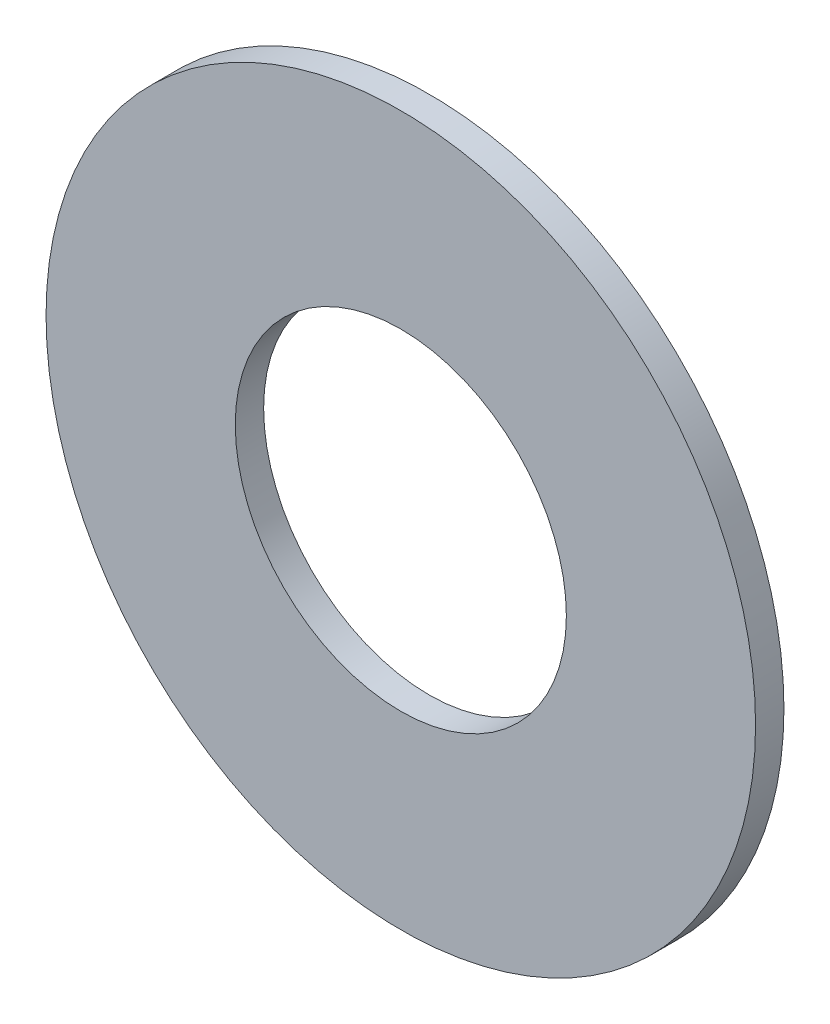
from build123d import *

# Parameters (mm, degrees)
SKETCH1_R           = 37.5
SKETCH1_R_2         = 17.5
BOSS_EXTRUDE1_DEPTH = 3


with BuildPart() as part:
    # Sketch1 → Boss-Extrude1 (new body)
    with BuildSketch(Plane.XY):
        Circle(SKETCH1_R)
        Circle(SKETCH1_R_2, mode=Mode.SUBTRACT)
    extrude(amount=BOSS_EXTRUDE1_DEPTH)


solid = part.part
